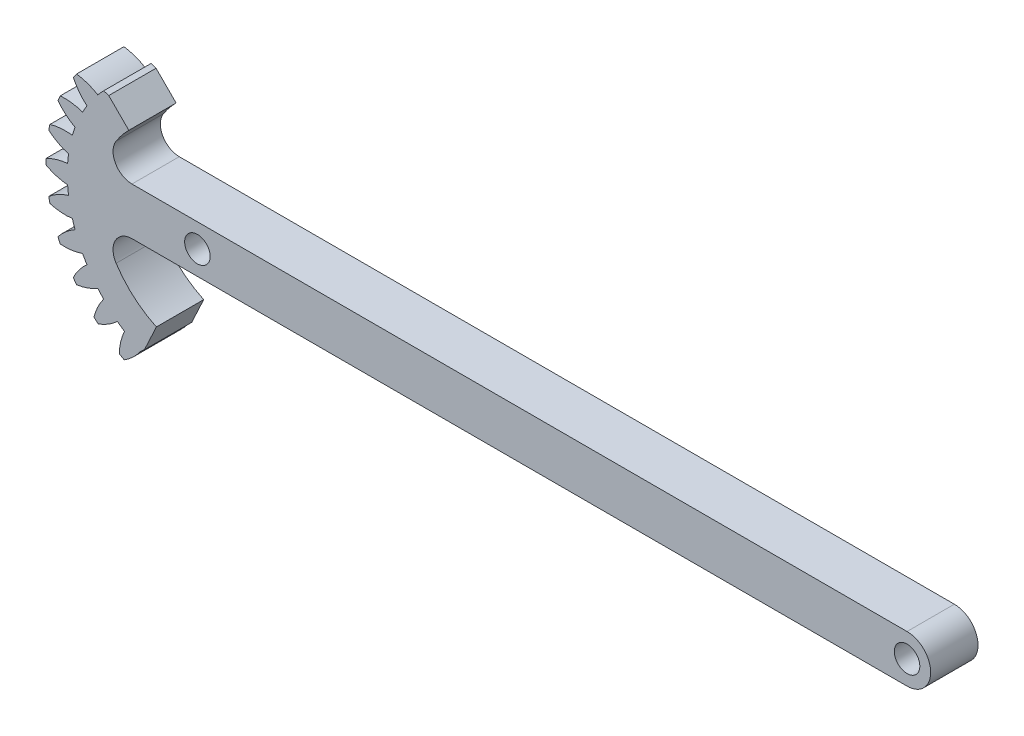
from build123d import *

# Parameters (mm, degrees)
SKETCH1_R                       = 2.7
BOSS_EXTRUDE1_DEPTH             = 5
BOSS_EXTRUDE2_REACH             = 157.161
BOSS_EXTRUDE2_DIRECTION_2_REACH = 157.161
FILLET1_R                       = 4
BOSS_EXTRUDE3_REACH             = 158.929
BOSS_EXTRUDE3_DIRECTION_2_REACH = 158.929


with BuildPart() as part:
    # Sketch1 → Boss-Extrude1 (new, symmetric)
    with BuildSketch(Plane.XY):
        with BuildLine():
            Line((0, 5), (150, 5))
            ThreePointArc((150, 5), (155, 0), (150, -5))
            Line((150, -5), (0, -5))
            ThreePointArc((0, -5), (-5, 0), (0, 5))
        make_face()
        Circle(SKETCH1_R, mode=Mode.SUBTRACT)
        with Locations((150, 0)):
            Circle(SKETCH1_R, mode=Mode.SUBTRACT)
    extrude(amount=BOSS_EXTRUDE1_DEPTH, both=True)

    # Boss-Extrude2: up to this face of the body (flat: up to its plane)
    boss_extrude2_end = Plane(part.part.faces().sort_by_distance((75, 0, 5))[0])
    # Sketch2 → Boss-Extrude2 (add, up to the picked face)
    with BuildSketch(Plane.XY, mode=Mode.PRIVATE) as boss_extrude2_sk1:
        with BuildLine():
            Line((0, 5), (-19.880895352, 5))
            ThreePointArc((-19.880895352, 5), (-17.831977334, 10.112891988), (-14.495689014, 14.495689014))
            Line((-14.495689014, 14.495689014), (-18.738329701, 18.738329701))
            ThreePointArc((-18.738329701, 18.738329701), (-26.097405455, -4.601676708), (-11.199383936, -24.017156356))
            Line((-11.199383936, -24.017156356), (-8.663674366, -18.579309634))
            ThreePointArc((-8.663674366, -18.579309634), (-15.804984265, -13.055744803), (-19.880895352, -5))
            Line((-19.880895352, -5), (0, -5))
            ThreePointArc((0, -5), (-5, 0), (0, 5))
        make_face()
    boss_extrude2_tool1 = split(extrude(boss_extrude2_sk1.sketch, amount=BOSS_EXTRUDE2_REACH, mode=Mode.PRIVATE), bisect_by=boss_extrude2_end, keep=Keep.BOTH, mode=Mode.PRIVATE)
    add(boss_extrude2_tool1.solids().sort_by(Axis((-16.92377, -2.181901, 0), (0, 0, 1)))[0])

    # Boss-Extrude2 direction 2: up to this face of the body (flat: up to its plane)
    boss_extrude2_direction_2_end = Plane(part.part.faces().sort_by_distance((75, 0, -5))[0])
    # Sketch2 → Boss-Extrude2 direction 2 (add, up to the picked face)
    with BuildSketch(Plane.XY, mode=Mode.PRIVATE) as boss_extrude2_direction_2_sk1:
        with BuildLine():
            Line((0, 5), (-19.880895352, 5))
            ThreePointArc((-19.880895352, 5), (-17.831977334, 10.112891988), (-14.495689014, 14.495689014))
            Line((-14.495689014, 14.495689014), (-18.738329701, 18.738329701))
            ThreePointArc((-18.738329701, 18.738329701), (-26.097405455, -4.601676708), (-11.199383936, -24.017156356))
            Line((-11.199383936, -24.017156356), (-8.663674366, -18.579309634))
            ThreePointArc((-8.663674366, -18.579309634), (-15.804984265, -13.055744803), (-19.880895352, -5))
            Line((-19.880895352, -5), (0, -5))
            ThreePointArc((0, -5), (-5, 0), (0, 5))
        make_face()
    boss_extrude2_direction_2_tool1 = split(extrude(boss_extrude2_direction_2_sk1.sketch, amount=-BOSS_EXTRUDE2_DIRECTION_2_REACH, mode=Mode.PRIVATE), bisect_by=boss_extrude2_direction_2_end, keep=Keep.BOTH, mode=Mode.PRIVATE)
    add(boss_extrude2_direction_2_tool1.solids().sort_by(Axis((-16.92377, -2.181901, 0), (0, 0, -1)))[0])

    # Fillet1
    fillet1_edges = [part.edges().sort_by_distance(p)[0] for p in [
        (-19.880895352, 5, 0),
        (-19.880895352, -5, 0),
    ]]
    fillet(fillet1_edges, radius=FILLET1_R)

    # Boss-Extrude3: up to this face of the body (flat: up to its plane)
    boss_extrude3_end = Plane(part.part.faces().sort_by_distance((54.007217668, -0.477206408, 5))[0])
    # Sketch3 → Boss-Extrude3 (add, up to the picked face)
    with BuildSketch(Plane.XY, mode=Mode.PRIVATE) as boss_extrude3_sk1:
        with BuildLine():
            Line((-19.809704653, 19.072771234), (-18.738329701, 18.738329701))
            ThreePointArc((-18.738329701, 18.738329701), (-26.097405455, -4.601676708), (-11.199383936, -24.017156356))
            Line((-11.199383936, -24.017156356), (-12.017747974, -24.733959138))
            ThreePointArc((-12.017747974, -24.733959138), (-13.582620769, -26.544741188), (-15.475712613, -28.008968548))
            ThreePointArc((-15.475712613, -28.008968548), (-16, -27.712812921), (-16.518621989, -27.406844539))
            ThreePointArc((-16.518621989, -27.406844539), (-16.197109821, -25.035265229), (-15.411362962, -22.774654611))
            ThreePointArc((-15.411362962, -22.774654611), (-16.163506653, -22.247158328), (-16.897610612, -21.694832486))
            ThreePointArc((-16.897610612, -21.694832486), (-18.804769939, -23.140689255), (-20.960923171, -24.179323808))
            ThreePointArc((-20.960923171, -24.179323808), (-21.412179403, -23.780634415), (-21.855853854, -23.373524601))
            ThreePointArc((-21.855853854, -23.373524601), (-21.048288434, -21.120616129), (-19.809704653, -19.072771234))
            ThreePointArc((-19.809704653, -19.072771234), (-20.435739556, -18.400422544), (-21.038966583, -17.707537551))
            ThreePointArc((-21.038966583, -17.707537551), (-23.205060428, -18.725278161), (-25.530040805, -19.292926592))
            ThreePointArc((-25.530040805, -19.292926592), (-25.88854382, -18.809128073), (-26.23788003, -18.31866948))
            ThreePointArc((-26.23788003, -18.31866948), (-24.979555842, -16.282894755), (-23.342267194, -14.537316233))
            ThreePointArc((-23.342267194, -14.537316233), (-23.814832579, -13.7495), (-24.260818757, -12.946338255))
            ThreePointArc((-24.260818757, -12.946338255), (-26.591178426, -13.491482557), (-28.983373149, -13.563335907))
            ThreePointArc((-28.983373149, -13.563335907), (-29.233454645, -13.015572578), (-29.473184945, -12.4632006))
            ThreePointArc((-29.473184945, -12.4632006), (-27.819096794, -10.733532747), (-25.854660649, -9.366510754))
            ThreePointArc((-25.854660649, -9.366510754), (-26.153103142, -8.497658328), (-26.422356736, -7.619321854))
            ThreePointArc((-26.422356736, -7.619321854), (-28.815134328, -7.668044426), (-31.169993008, -7.240962359))
            ThreePointArc((-31.169993008, -7.240962359), (-31.300723223, -6.653174106), (-31.42037025, -6.063030049))
            ThreePointArc((-31.42037025, -6.063030049), (-29.442809726, -4.715063852), (-27.23708137, -3.786343811))
            ThreePointArc((-27.23708137, -3.786343811), (-27.348357601, -2.874428211), (-27.429110937, -1.959304527))
            ThreePointArc((-27.429110937, -1.959304527), (-29.77973059, -1.509475958), (-31.994334603, -0.602124009))
            ThreePointArc((-31.994334603, -0.602124009), (-32, 0), (-31.994334603, 0.602124009))
            ThreePointArc((-31.994334603, 0.602124009), (-29.77973059, 1.509475958), (-27.429110937, 1.959304527))
            ThreePointArc((-27.429110937, 1.959304527), (-27.348357601, 2.874428211), (-27.23708137, 3.786343811))
            ThreePointArc((-27.23708137, 3.786343811), (-29.442809726, 4.715063852), (-31.42037025, 6.063030049))
            ThreePointArc((-31.42037025, 6.063030049), (-31.300723223, 6.653174106), (-31.169993008, 7.240962359))
            ThreePointArc((-31.169993008, 7.240962359), (-28.815134328, 7.668044426), (-26.422356736, 7.619321854))
            ThreePointArc((-26.422356736, 7.619321854), (-26.153103142, 8.497658328), (-25.854660649, 9.366510754))
            ThreePointArc((-25.854660649, 9.366510754), (-27.819096794, 10.733532747), (-29.473184945, 12.4632006))
            ThreePointArc((-29.473184945, 12.4632006), (-29.233454645, 13.015572578), (-28.983373149, 13.563335907))
            ThreePointArc((-28.983373149, 13.563335907), (-26.591178426, 13.491482557), (-24.260818757, 12.946338255))
            ThreePointArc((-24.260818757, 12.946338255), (-23.814832579, 13.7495), (-23.342267194, 14.537316233))
            ThreePointArc((-23.342267194, 14.537316233), (-24.979555842, 16.282894755), (-26.23788003, 18.31866948))
            ThreePointArc((-26.23788003, 18.31866948), (-25.88854382, 18.809128073), (-25.530040805, 19.292926592))
            ThreePointArc((-25.530040805, 19.292926592), (-23.205060428, 18.725278161), (-21.038966583, 17.707537551))
            ThreePointArc((-21.038966583, 17.707537551), (-20.435739556, 18.400422544), (-19.809704653, 19.072771234))
        make_face()
    boss_extrude3_tool1 = split(extrude(boss_extrude3_sk1.sketch, amount=BOSS_EXTRUDE3_REACH, mode=Mode.PRIVATE), bisect_by=boss_extrude3_end, keep=Keep.BOTH, mode=Mode.PRIVATE)
    add(boss_extrude3_tool1.solids().sort_by(Axis((-23.367328, 13.491133, 0), (0, 0, 1)))[0])

    # Boss-Extrude3 direction 2: up to this face of the body (flat: up to its plane)
    boss_extrude3_direction_2_end = Plane(part.part.faces().sort_by_distance((54.007217668, -0.477206408, -5))[0])
    # Sketch3 → Boss-Extrude3 direction 2 (add, up to the picked face)
    with BuildSketch(Plane.XY, mode=Mode.PRIVATE) as boss_extrude3_direction_2_sk1:
        with BuildLine():
            Line((-19.809704653, 19.072771234), (-18.738329701, 18.738329701))
            ThreePointArc((-18.738329701, 18.738329701), (-26.097405455, -4.601676708), (-11.199383936, -24.017156356))
            Line((-11.199383936, -24.017156356), (-12.017747974, -24.733959138))
            ThreePointArc((-12.017747974, -24.733959138), (-13.582620769, -26.544741188), (-15.475712613, -28.008968548))
            ThreePointArc((-15.475712613, -28.008968548), (-16, -27.712812921), (-16.518621989, -27.406844539))
            ThreePointArc((-16.518621989, -27.406844539), (-16.197109821, -25.035265229), (-15.411362962, -22.774654611))
            ThreePointArc((-15.411362962, -22.774654611), (-16.163506653, -22.247158328), (-16.897610612, -21.694832486))
            ThreePointArc((-16.897610612, -21.694832486), (-18.804769939, -23.140689255), (-20.960923171, -24.179323808))
            ThreePointArc((-20.960923171, -24.179323808), (-21.412179403, -23.780634415), (-21.855853854, -23.373524601))
            ThreePointArc((-21.855853854, -23.373524601), (-21.048288434, -21.120616129), (-19.809704653, -19.072771234))
            ThreePointArc((-19.809704653, -19.072771234), (-20.435739556, -18.400422544), (-21.038966583, -17.707537551))
            ThreePointArc((-21.038966583, -17.707537551), (-23.205060428, -18.725278161), (-25.530040805, -19.292926592))
            ThreePointArc((-25.530040805, -19.292926592), (-25.88854382, -18.809128073), (-26.23788003, -18.31866948))
            ThreePointArc((-26.23788003, -18.31866948), (-24.979555842, -16.282894755), (-23.342267194, -14.537316233))
            ThreePointArc((-23.342267194, -14.537316233), (-23.814832579, -13.7495), (-24.260818757, -12.946338255))
            ThreePointArc((-24.260818757, -12.946338255), (-26.591178426, -13.491482557), (-28.983373149, -13.563335907))
            ThreePointArc((-28.983373149, -13.563335907), (-29.233454645, -13.015572578), (-29.473184945, -12.4632006))
            ThreePointArc((-29.473184945, -12.4632006), (-27.819096794, -10.733532747), (-25.854660649, -9.366510754))
            ThreePointArc((-25.854660649, -9.366510754), (-26.153103142, -8.497658328), (-26.422356736, -7.619321854))
            ThreePointArc((-26.422356736, -7.619321854), (-28.815134328, -7.668044426), (-31.169993008, -7.240962359))
            ThreePointArc((-31.169993008, -7.240962359), (-31.300723223, -6.653174106), (-31.42037025, -6.063030049))
            ThreePointArc((-31.42037025, -6.063030049), (-29.442809726, -4.715063852), (-27.23708137, -3.786343811))
            ThreePointArc((-27.23708137, -3.786343811), (-27.348357601, -2.874428211), (-27.429110937, -1.959304527))
            ThreePointArc((-27.429110937, -1.959304527), (-29.77973059, -1.509475958), (-31.994334603, -0.602124009))
            ThreePointArc((-31.994334603, -0.602124009), (-32, 0), (-31.994334603, 0.602124009))
            ThreePointArc((-31.994334603, 0.602124009), (-29.77973059, 1.509475958), (-27.429110937, 1.959304527))
            ThreePointArc((-27.429110937, 1.959304527), (-27.348357601, 2.874428211), (-27.23708137, 3.786343811))
            ThreePointArc((-27.23708137, 3.786343811), (-29.442809726, 4.715063852), (-31.42037025, 6.063030049))
            ThreePointArc((-31.42037025, 6.063030049), (-31.300723223, 6.653174106), (-31.169993008, 7.240962359))
            ThreePointArc((-31.169993008, 7.240962359), (-28.815134328, 7.668044426), (-26.422356736, 7.619321854))
            ThreePointArc((-26.422356736, 7.619321854), (-26.153103142, 8.497658328), (-25.854660649, 9.366510754))
            ThreePointArc((-25.854660649, 9.366510754), (-27.819096794, 10.733532747), (-29.473184945, 12.4632006))
            ThreePointArc((-29.473184945, 12.4632006), (-29.233454645, 13.015572578), (-28.983373149, 13.563335907))
            ThreePointArc((-28.983373149, 13.563335907), (-26.591178426, 13.491482557), (-24.260818757, 12.946338255))
            ThreePointArc((-24.260818757, 12.946338255), (-23.814832579, 13.7495), (-23.342267194, 14.537316233))
            ThreePointArc((-23.342267194, 14.537316233), (-24.979555842, 16.282894755), (-26.23788003, 18.31866948))
            ThreePointArc((-26.23788003, 18.31866948), (-25.88854382, 18.809128073), (-25.530040805, 19.292926592))
            ThreePointArc((-25.530040805, 19.292926592), (-23.205060428, 18.725278161), (-21.038966583, 17.707537551))
            ThreePointArc((-21.038966583, 17.707537551), (-20.435739556, 18.400422544), (-19.809704653, 19.072771234))
        make_face()
    boss_extrude3_direction_2_tool1 = split(extrude(boss_extrude3_direction_2_sk1.sketch, amount=-BOSS_EXTRUDE3_DIRECTION_2_REACH, mode=Mode.PRIVATE), bisect_by=boss_extrude3_direction_2_end, keep=Keep.BOTH, mode=Mode.PRIVATE)
    add(boss_extrude3_direction_2_tool1.solids().sort_by(Axis((-23.367328, 13.491133, 0), (0, 0, -1)))[0])


solid = part.part
